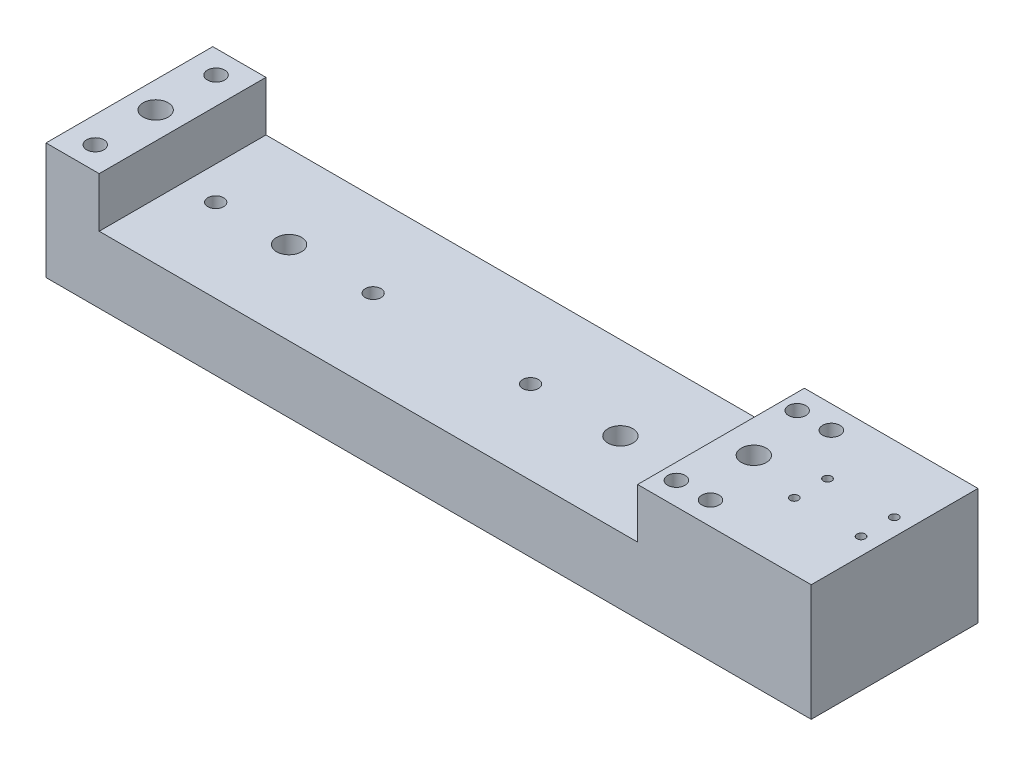
from build123d import *

# Parameters (mm, degrees)
SKETCH1_W                       = 41.1
SKETCH1_H                       = 38.05
MAIN_EXTRUDE_DEPTH              = 63.5
SKETCH3_R                       = 3.3
RAIL_BLOCK_MOUNTING_HOLES_DEPTH = 6.35
SKETCH4_R                       = 1.5875
MOTOR_MOUNTING_HOLES_DEPTH      = 6.35
SKETCH8_R                       = 3
RAIL_MOUNTING_HOLES_DEPTH       = 6.35
SKETCH5_R                       = 3.31216
CUT_EXTRUDE3_DEPTH              = 39.05
CUT_EXTRUDE3_DEPTH_BACK         = 7.35
SKETCH7_R                       = 4.7625
CUT_EXTRUDE6_DEPTH              = 32.7


with BuildPart() as part:
    # Sketch1 → Main Extrude (new body)
    with BuildSketch(Plane.XY):
        Polygon((125.125, 0), (-125.125, 0), (-125.125, -6.35), (166.225, -6.35), (166.225, 0), align=None)
        Polygon((-125.125, 38.05), (-125.125, 0), (125.125, 0), (125.125, 38.05), (100.125, 38.05), (100.125, 19.05), (-104.875, 19.05), (-104.875, 38.05), align=None)
        with Locations((145.675, 19.025)):
            Rectangle(SKETCH1_W, SKETCH1_H)
    extrude(amount=MAIN_EXTRUDE_DEPTH)

    # Sketch3 → Rail Block Mounting Holes (cut)
    with BuildSketch(Plane(origin=(0, 38.05, 0), x_dir=(1, 0, 0), z_dir=(0, 1, 0))):
        with Locations((106.125, -54.75)):
            Circle(SKETCH3_R)
        with Locations((119.125, -54.75)):
            Circle(SKETCH3_R)
        with Locations((106.125, -8.75)):
            Circle(SKETCH3_R)
        with Locations((119.125, -8.75)):
            Circle(SKETCH3_R)
        with Locations((-115.125, -54.75)):
            Circle(SKETCH3_R)
        with Locations((-115.125, -8.75)):
            Circle(SKETCH3_R)
    extrude(amount=-RAIL_BLOCK_MOUNTING_HOLES_DEPTH, mode=Mode.SUBTRACT)

    # Sketch4 → Motor Mounting Holes (cut)
    with BuildSketch(Plane(origin=(0, 38.05, 0), x_dir=(1, 0, 0), z_dir=(0, 1, 0))):
        with Locations((134.373571068, -25.432199749)):
            Circle(SKETCH4_R)
        with Locations((159.773570419, -25.426458163)):
            Circle(SKETCH4_R)
        with Locations((159.77642991, -38.07645784)):
            Circle(SKETCH4_R)
        with Locations((134.376430559, -38.082199426)):
            Circle(SKETCH4_R)
    extrude(amount=-MOTOR_MOUNTING_HOLES_DEPTH, mode=Mode.SUBTRACT)

    # Sketch8 → Rail Mounting Holes (cut)
    with BuildSketch(Plane(origin=(0, 19.05, 0), x_dir=(1, 0, 0), z_dir=(0, 1, 0))):
        with Locations((87.625, -31.75)):
            Circle(SKETCH8_R)
        with Locations((27.625, -31.75)):
            Circle(SKETCH8_R)
        with Locations((-32.319, -31.75)):
            Circle(SKETCH8_R)
        with Locations((-92.263, -31.75)):
            Circle(SKETCH8_R)
    extrude(amount=-RAIL_MOUNTING_HOLES_DEPTH, mode=Mode.SUBTRACT)

    # Sketch5 → Cut-Extrude3 (cut, two sides)
    with BuildSketch(Plane(origin=(0, 0, 0), x_dir=(1, 0, 0), z_dir=(0, 1, 0))) as cut_extrude3_sk:
        with Locations((-115.125, -31.75)):
            Circle(SKETCH5_R)
        with Locations((-64.325, -31.75)):
            Circle(SKETCH5_R)
        with Locations((61.825, -31.75)):
            Circle(SKETCH5_R)
        with Locations((112.625, -31.75)):
            Circle(SKETCH5_R)
    extrude(amount=CUT_EXTRUDE3_DEPTH, mode=Mode.SUBTRACT)
    extrude(cut_extrude3_sk.sketch, amount=-CUT_EXTRUDE3_DEPTH_BACK, mode=Mode.SUBTRACT)

    # Sketch7 → Cut-Extrude6 (cut, through all)
    with BuildSketch(Plane(origin=(0, 6.35, 0), x_dir=(-1, 0, 0), z_dir=(0, -1, 0))):
        with Locations((115.125, -31.75)):
            Circle(SKETCH7_R)
        with Locations((64.325, -31.75)):
            Circle(SKETCH7_R)
        with Locations((-112.625, -31.75)):
            Circle(SKETCH7_R)
        with Locations((-61.825, -31.75)):
            Circle(SKETCH7_R)
    extrude(amount=-CUT_EXTRUDE6_DEPTH, mode=Mode.SUBTRACT)


solid = part.part
